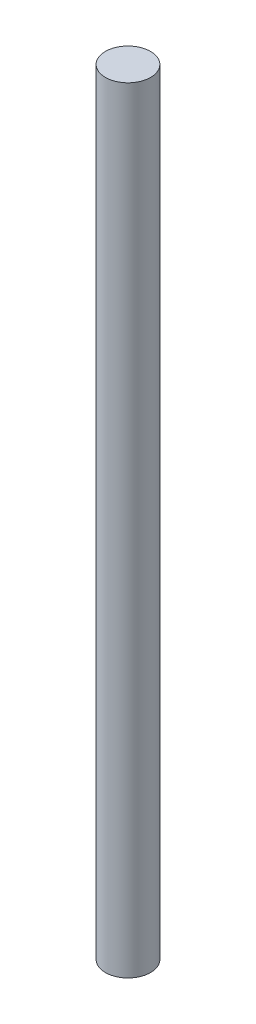
from build123d import *

# Parameters (mm, degrees)
CROQUIS1_R              = 3.2
SALIENTE_EXTRUIR1_DEPTH = 110


with BuildPart() as part:
    # Croquis1 → Saliente-Extruir1 (new body)
    with BuildSketch(Plane(origin=(0, 0, 0), x_dir=(1, 0, 0), z_dir=(0, 1, 0))):
        Circle(CROQUIS1_R)
    extrude(amount=SALIENTE_EXTRUIR1_DEPTH)


solid = part.part
